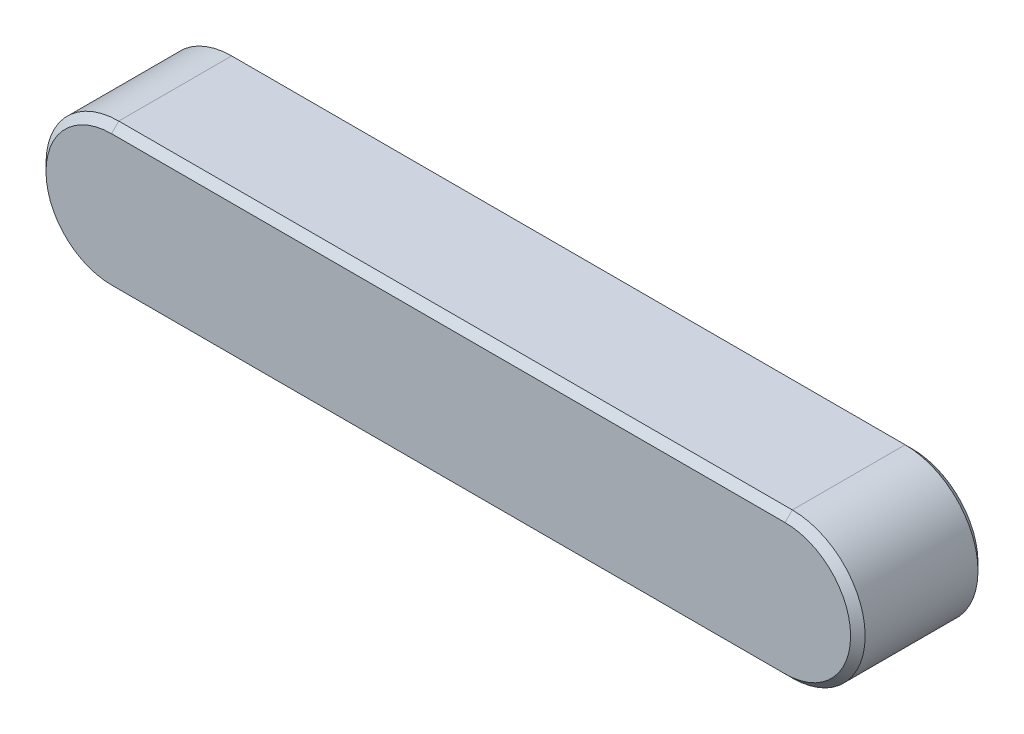
from build123d import *

# Parameters (mm, degrees)
BASEKEY_DEPTH = 3.5
CHAMFER1_SIZE = 0.4


with BuildPart() as part:
    # Sketch1 → BaseKey (new body, symmetric)
    with BuildSketch(Plane.XY):
        with BuildLine():
            Line((-37, 4), (0, 4))
            ThreePointArc((0, 4), (4, 0), (0, -4))
            Line((0, -4), (-37, -4))
            ThreePointArc((-37, -4), (-41, 0), (-37, 4))
        make_face()
    extrude(amount=BASEKEY_DEPTH, both=True)

    # Chamfer1
    chamfer1_edges = [part.edges().sort_by_distance(p)[0] for p in [
        (4, 0, 3.5),
        (-18.5, 4, 3.5),
        (-41, 0, 3.5),
        (-18.5, 4, -3.5),
        (4, 0, -3.5),
        (-18.5, -4, -3.5),
        (-41, 0, -3.5),
        (-18.5, -4, 3.5),
    ]]
    chamfer(chamfer1_edges, length=CHAMFER1_SIZE)


solid = part.part
